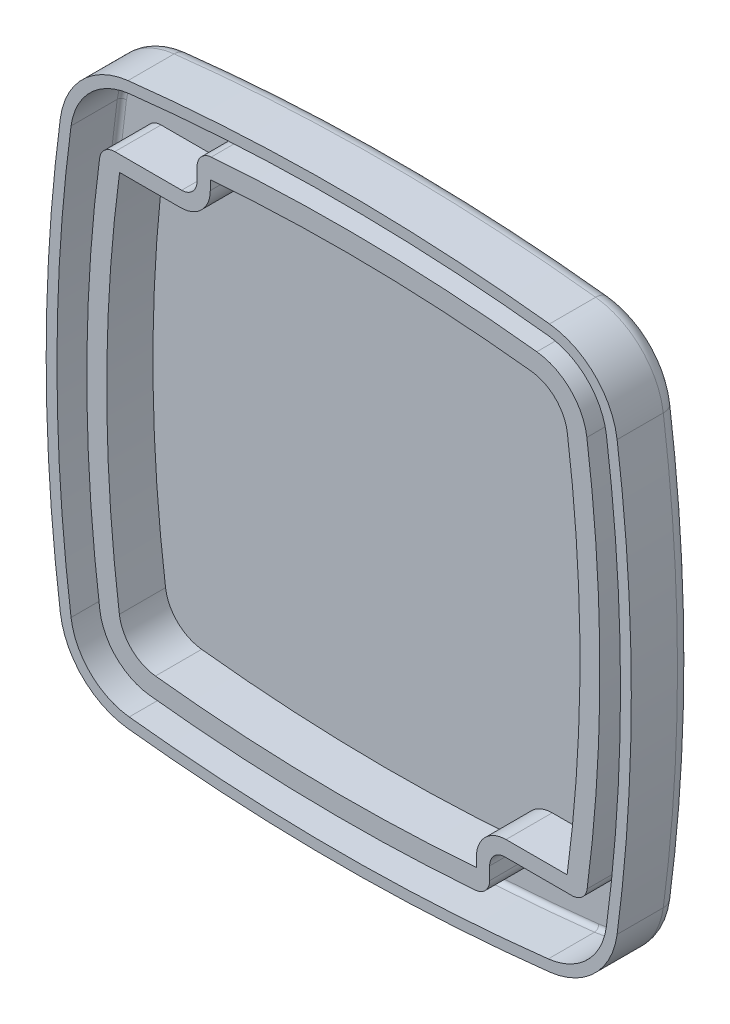
from build123d import *

# Parameters (mm, degrees)
IZIM1_W                      = 38
IZIM1_H                      = 38
Y_KSEKLIK_EKSTR_ZYON1_DEPTH  = 2
KES_EKSTR_ZYON1_DEPTH        = 5
KES_EKSTR_ZYON2_DEPTH        = 5
RADYUS1_R                    = 5
RADYUS2_R                    = 1
BO_ALTMA1_T                  = -0.7
Y_KSEKLIK_EKSTR_ZYON10_DEPTH = 3
KES_EKSTR_ZYON6_DEPTH        = 3
RADYUS3_R                    = 1
KES_EKSTR_ZYON7_DEPTH        = 3


with BuildPart() as part:
    # Çizim1 → Yükseklik-Ekstrüzyon1 (new body, symmetric)
    with BuildSketch(Plane.XY):
        Rectangle(IZIM1_W, IZIM1_H)
    extrude(amount=Y_KSEKLIK_EKSTR_ZYON1_DEPTH, both=True)

    # Çizim2 → Kes-Ekstrüzyon1 (cut, through all)
    with BuildSketch(Plane.XY.offset(2)):
        with BuildLine():
            Line((19, 19), (0, 19))
            ThreePointArc((0, 19), (9.529559276, 18.624417499), (19, 17.5))
            Line((19, 17.5), (19, 19))
        make_face()
        with BuildLine():
            Line((0, 19), (-19, 19))
            Line((-19, 19), (-19, 17.5))
            ThreePointArc((-19, 17.5), (-9.529559276, 18.624417499), (0, 19))
        make_face()
        with BuildLine():
            ThreePointArc((0, -19), (-9.529559276, -18.624417499), (-19, -17.5))
            Line((-19, -17.5), (-19, -19))
            Line((-19, -19), (0, -19))
        make_face()
        with BuildLine():
            Line((19, -19), (19, -17.5))
            ThreePointArc((19, -17.5), (9.529559276, -18.624417499), (0, -19))
            Line((0, -19), (19, -19))
        make_face()
    extrude(amount=-KES_EKSTR_ZYON1_DEPTH, mode=Mode.SUBTRACT)

    # Çizim3 → Kes-Ekstrüzyon2 (cut, through all)
    with BuildSketch(Plane.XY.offset(2)):
        with BuildLine():
            Line((19, 0), (19, 17.5))
            ThreePointArc((19, 17.5), (18.250358245, 17.61670023), (17.5, 17.728701167))
            ThreePointArc((17.5, 17.728701167), (18.624331272, 8.896022216), (19, 0))
        make_face()
        with BuildLine():
            Line((19, -17.5), (19, 0))
            ThreePointArc((19, 0), (18.624331272, -8.896022216), (17.5, -17.728701167))
            ThreePointArc((17.5, -17.728701167), (18.250358245, -17.61670023), (19, -17.5))
        make_face()
        with BuildLine():
            ThreePointArc((-19, -17.5), (-18.250358245, -17.61670023), (-17.5, -17.728701167))
            ThreePointArc((-17.5, -17.728701167), (-18.624331272, -8.896022216), (-19, 0))
            Line((-19, 0), (-19, -17.5))
        make_face()
        with BuildLine():
            ThreePointArc((-19, 0), (-18.624331272, 8.896022216), (-17.5, 17.728701167))
            ThreePointArc((-17.5, 17.728701167), (-18.250358245, 17.61670023), (-19, 17.5))
            Line((-19, 17.5), (-19, 0))
        make_face()
    extrude(amount=-KES_EKSTR_ZYON2_DEPTH, mode=Mode.SUBTRACT)

    # Radyus1
    radyus1_edges = [part.edges().sort_by_distance(p)[0] for p in [
        (17.5, 17.728701167, 0),
        (17.5, -17.728701167, 0),
        (-17.5, -17.728701167, 0),
        (-17.5, 17.728701167, 0),
    ]]
    fillet(radyus1_edges, radius=RADYUS1_R)

    # Radyus2
    radyus2_edges = [part.edges().sort_by_distance(p)[0] for p in [
        (-19, 0, -2),
        (0, -19, -2),
        (0, 19, -2),
        (19, 0, -2),
        (16.62392767, 16.824874803, -2),
        (-16.62392767, 16.824874803, -2),
        (16.62392767, -16.824874803, -2),
        (-16.62392767, -16.824874803, -2),
    ]]
    fillet(radyus2_edges, radius=RADYUS2_R)

    # İç Boşaltma1
    bo_altma1_openings = [part.faces().sort_by_distance(p)[0] for p in [
        (0, 0, 2),
    ]]
    offset(amount=BO_ALTMA1_T, openings=bo_altma1_openings)


with BuildPart() as body_2:
    # Çizim10 → Yükseklik-Ekstrüzyon10 (new body)
    with BuildSketch(Plane.XY.offset(-1.3)):
        with BuildLine():
            ThreePointArc((12.563728068, 15.947604972), (0, 16.65999216), (-12.563728068, 15.947604972))
            ThreePointArc((-12.563728068, 15.947604972), (-14.738134647, 14.911702064), (-15.815114277, 12.757345157))
            ThreePointArc((-15.815114277, 12.757345157), (-16.65999216, 0), (-15.815114277, -12.757345157))
            ThreePointArc((-15.815114277, -12.757345157), (-14.738134647, -14.911702064), (-12.563728068, -15.947604972))
            ThreePointArc((-12.563728068, -15.947604972), (0, -16.65999216), (12.563728068, -15.947604972))
            ThreePointArc((12.563728068, -15.947604972), (14.738134647, -14.911702064), (15.815114277, -12.757345157))
            ThreePointArc((15.815114277, -12.757345157), (16.65999216, 0), (15.815114277, 12.757345157))
            ThreePointArc((15.815114277, 12.757345157), (14.738134647, 14.911702064), (12.563728068, 15.947604972))
        make_face()
    extrude(amount=Y_KSEKLIK_EKSTR_ZYON10_DEPTH)

    # Çizim14 → Kes-Ekstrüzyon6 (cut)
    with BuildSketch(Plane.XY.offset(1.7)):
        Polygon((9.5, -17.166486322), (14.818678907, -15.969147287), (16.574424724, -13.5), (9.5, -13.5), align=None)
        Polygon((-16.526203584, 13.5), (-9.5, 13.5), (-9.5, 17.124208081), (-15.492949515, 15.319045047), align=None)
    extrude(amount=-KES_EKSTR_ZYON6_DEPTH, mode=Mode.SUBTRACT)

    # Radyus3
    radyus3_edges = [body_2.edges().sort_by_distance(p)[0] for p in [
        (-15.636840101, 13.5, 0.2),
        (-9.5, 13.5, 0.2),
        (-9.5, 16.253242116, 0.2),
        (9.5, -16.253242116, 0.2),
        (9.5, -13.5, 0.2),
        (15.636840101, -13.5, 0.2),
    ]]
    fillet(radyus3_edges, radius=RADYUS3_R)

    # Çizim15 → Kes-Ekstrüzyon7 (cut)
    with BuildSketch(Plane.XY.offset(1.7)):
        with BuildLine():
            Line((8.6436, -15.019821331), (8.6436, -14.406))
            ThreePointArc((8.6436, -14.406), (9.206189295, -13.047789295), (10.5644, -12.4852))
            Line((10.5644, -12.4852), (14.529884127, -12.4852))
            ThreePointArc((14.529884127, -12.4852), (14.538912089, -12.430460626), (14.546799805, -12.375545354))
            ThreePointArc((14.546799805, -12.375545354), (15.366392317, 0), (14.546799805, 12.375545354))
            ThreePointArc((14.546799805, 12.375545354), (13.770741086, 13.927949333), (12.203889551, 14.674408655))
            ThreePointArc((12.203889551, 14.674408655), (1.788502978, 15.351576883), (-8.6436, 15.019821331))
            Line((-8.6436, 15.019821331), (-8.6436, 14.406))
            ThreePointArc((-8.6436, 14.406), (-9.206189295, 13.047789295), (-10.5644, 12.4852))
            Line((-10.5644, 12.4852), (-14.529884127, 12.4852))
            ThreePointArc((-14.529884127, 12.4852), (-14.538912089, 12.430460626), (-14.546799805, 12.375545354))
            ThreePointArc((-14.546799805, 12.375545354), (-15.366392317, 0), (-14.546799805, -12.375545354))
            ThreePointArc((-14.546799805, -12.375545354), (-13.770741086, -13.927949333), (-12.203889551, -14.674408655))
            ThreePointArc((-12.203889551, -14.674408655), (-1.788502978, -15.351576883), (8.6436, -15.019821331))
        make_face()
    extrude(amount=-KES_EKSTR_ZYON7_DEPTH, mode=Mode.SUBTRACT)


solid = Compound([part.part, body_2.part])
